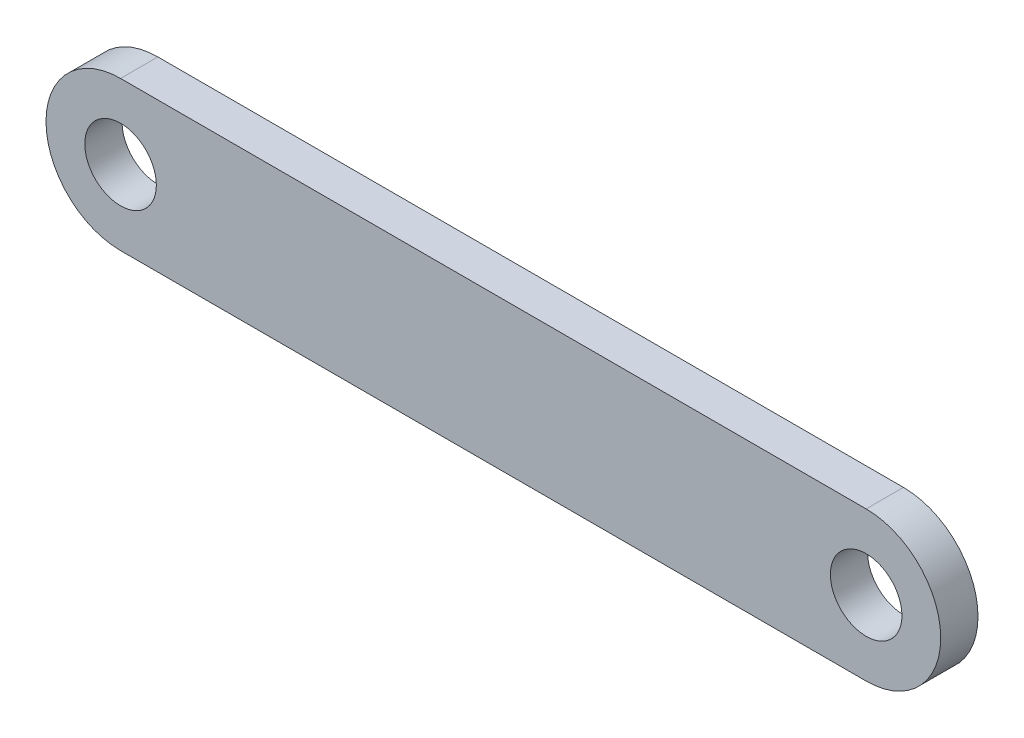
from build123d import *

# Parameters (mm, degrees)
SKETCH1_R           = 3.048
BOSS_EXTRUDE1_DEPTH = 3.175


with BuildPart() as part:
    # Sketch1 → Boss-Extrude1 (new body)
    with BuildSketch(Plane.XY):
        with BuildLine():
            Line((-31.75, -6.35), (31.75, -6.35))
            ThreePointArc((31.75, -6.35), (38.1, 0), (31.75, 6.35))
            Line((31.75, 6.35), (-31.75, 6.35))
            ThreePointArc((-31.75, 6.35), (-38.1, 0), (-31.75, -6.35))
        make_face()
        with Locations((31.75, 0)):
            Circle(SKETCH1_R, mode=Mode.SUBTRACT)
        with Locations((-31.75, 0)):
            Circle(SKETCH1_R, mode=Mode.SUBTRACT)
    extrude(amount=BOSS_EXTRUDE1_DEPTH)


solid = part.part
